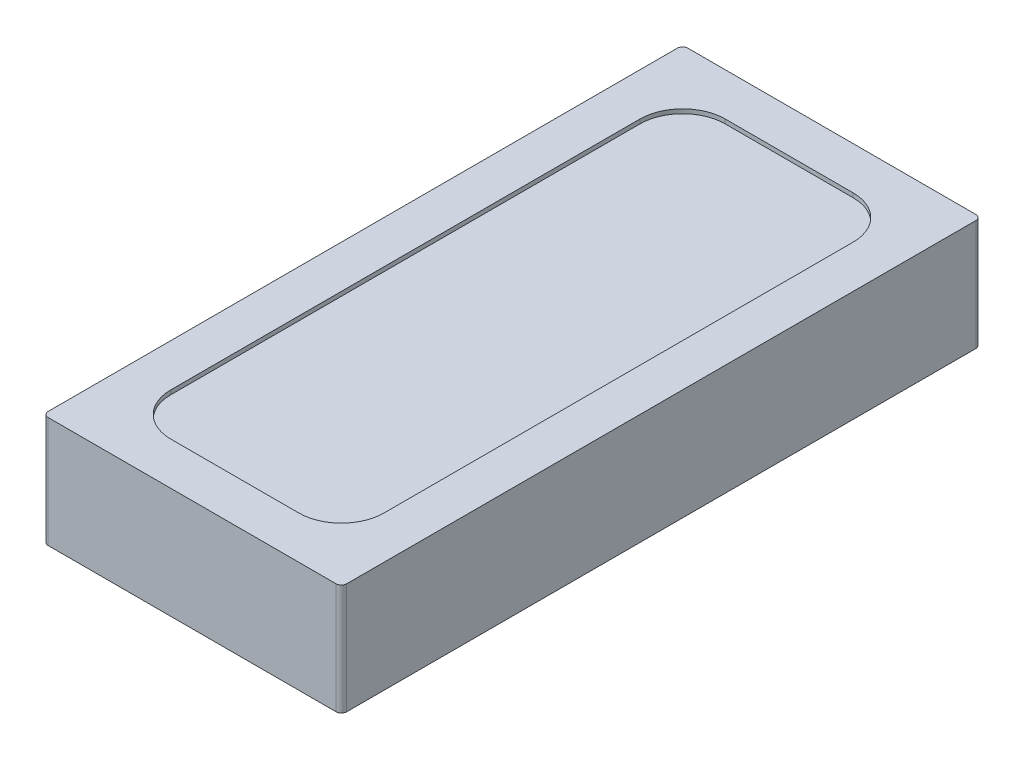
from build123d import *

# Parameters (mm, degrees)
BOSS_EXTRUDE1_DEPTH = 0.52
CUT_EXTRUDE1_DEPTH  = 0.02


with BuildPart() as part:
    # Sketch1 → Boss-Extrude1 (new body)
    with BuildSketch(Plane(origin=(0, 0, 0), x_dir=(1, 0, 0), z_dir=(0, 1, 0))):
        with BuildLine():
            Line((-0.675, -1.5), (0.675, -1.5))
            ThreePointArc((0.675, -1.5), (0.69267767, -1.49267767), (0.7, -1.475))
            Line((0.7, -1.475), (0.7, 1.475))
            ThreePointArc((0.7, 1.475), (0.69267767, 1.49267767), (0.675, 1.5))
            Line((0.675, 1.5), (-0.675, 1.5))
            ThreePointArc((-0.675, 1.5), (-0.69267767, 1.49267767), (-0.7, 1.475))
            Line((-0.7, 1.475), (-0.7, -1.475))
            ThreePointArc((-0.7, -1.475), (-0.69267767, -1.49267767), (-0.675, -1.5))
        make_face()
    extrude(amount=BOSS_EXTRUDE1_DEPTH)

    # Sketch2 → Cut-Extrude1 (cut)
    with BuildSketch(Plane(origin=(0, 0.52, 0), x_dir=(1, 0, 0), z_dir=(0, 1, 0))):
        with BuildLine():
            Line((-0.3, -1.3), (0.3, -1.3))
            ThreePointArc((0.3, -1.3), (0.441421356, -1.241421356), (0.5, -1.1))
            Line((0.5, -1.1), (0.5, 1.1))
            ThreePointArc((0.5, 1.1), (0.441421356, 1.241421356), (0.3, 1.3))
            Line((0.3, 1.3), (-0.3, 1.3))
            ThreePointArc((-0.3, 1.3), (-0.441421356, 1.241421356), (-0.5, 1.1))
            Line((-0.5, 1.1), (-0.5, -1.1))
            ThreePointArc((-0.5, -1.1), (-0.441421356, -1.241421356), (-0.3, -1.3))
        make_face()
    extrude(amount=-CUT_EXTRUDE1_DEPTH, mode=Mode.SUBTRACT)


solid = part.part
